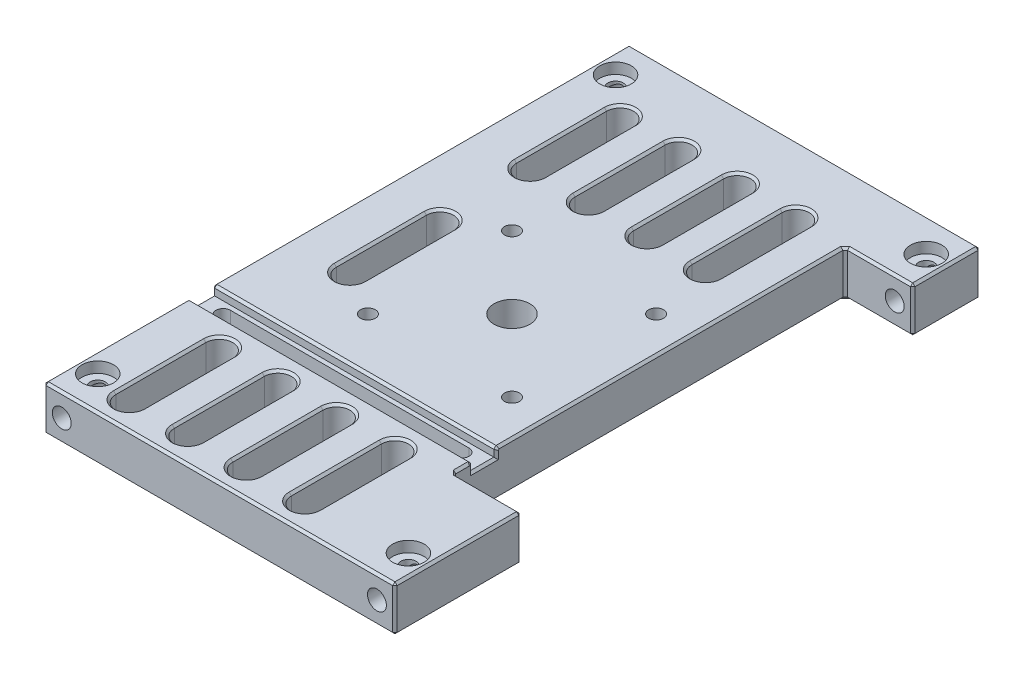
from build123d import *

# Parameters (mm, degrees)
ESQUISSE1_W                                        = 78
ESQUISSE1_H                                        = 10
BOSS_EXTRU_1_DEPTH                                 = 130
TROU_TARAUD_M5X0_81_D                              = 4.2
TROU_TARAUD_M5X0_81_DEPTH                          = 20
TROU_TARAUD_M5X0_81_TIP                            = 1.2618073
TROU_TARAUD_M5X0_82_D                              = 4.2
TROU_TARAUD_M5X0_82_DEPTH                          = 20
TROU_TARAUD_M5X0_82_TIP                            = 1.2618073
TROU_TARAUD_3_8_161_D                              = 7.9375
ESQUISSE9_W                                        = 28.652769352
ESQUISSE9_H                                        = 87
ENL_V_MAT_EXTRU_1_DEPTH                            = 11
ESQUISSE10_W                                       = 68.548519831
ESQUISSE10_H                                       = 5.2
ENL_V_MAT_EXTRU_2_DEPTH                            = 2
CHANFREIN1_SIZE                                    = 0.5
ENL_V_MAT_EXTRU_3_DEPTH                            = 11
ENL_V_MAT_EXTRU_4_DEPTH                            = 3.5
TROU_TARAUD_M4X0_71_D                              = 3.3
TROU_TARAUD_M4X0_71_DEPTH                          = 10
CHAMBRAGE_POUR_VIS_T_TE_RONDE_BOMB_E_M_D           = 3.4
CHAMBRAGE_POUR_VIS_T_TE_RONDE_BOMB_E_M_CBORE_D     = 7
CHAMBRAGE_POUR_VIS_T_TE_RONDE_BOMB_E_M_CBORE_DEPTH = 2.4
ENL_V_MAT_EXTRU_5_DEPTH                            = 10
CHANFREIN2_SIZE                                    = 0.5
CHANFREIN3_SIZE                                    = 0.5


with BuildPart() as part:
    # Esquisse1 → Boss.-Extru.1 (new body)
    with BuildSketch(Plane.XY):
        with Locations((0, -4.782828283)):
            Rectangle(ESQUISSE1_W, ESQUISSE1_H)
    extrude(amount=BOSS_EXTRU_1_DEPTH)

    # Trou taraudé M5x0.81
    with Locations(Plane(origin=(-35, -4.782828283, 130), x_dir=(1, 0, 0), z_dir=(0, 0, 1))):
        with Locations((0, 0), (70, 0)):
            Hole(TROU_TARAUD_M5X0_81_D / 2, depth=TROU_TARAUD_M5X0_81_DEPTH)
            with Locations((0, 0, -(TROU_TARAUD_M5X0_81_DEPTH + TROU_TARAUD_M5X0_81_TIP / 2))):  # 118° drill point
                Cone(0, TROU_TARAUD_M5X0_81_D / 2, TROU_TARAUD_M5X0_81_TIP, mode=Mode.SUBTRACT)

    # Trou taraudé M5x0.82
    with Locations(Plane(origin=(0, 0, 0), x_dir=(-1, 0, 0), z_dir=(0, 0, -1))):
        with Locations((-35, -4.782828283), (35, -4.782828283)):
            Hole(TROU_TARAUD_M5X0_82_D / 2, depth=TROU_TARAUD_M5X0_82_DEPTH)
            with Locations((0, 0, -(TROU_TARAUD_M5X0_82_DEPTH + TROU_TARAUD_M5X0_82_TIP / 2))):  # 118° drill point
                Cone(0, TROU_TARAUD_M5X0_82_D / 2, TROU_TARAUD_M5X0_82_TIP, mode=Mode.SUBTRACT)

    # Trou taraudé 3/8-161 (through all)
    with Locations(Plane(origin=(0, -9.782828283, 65), x_dir=(0, 0, -1), z_dir=(0, -1, 0))):
        with Locations((0, 0)):
            Hole(TROU_TARAUD_3_8_161_D / 2)

    # Esquisse9 → Enlèv. mat.-Extru.1 (cut, through all)
    with BuildSketch(Plane(origin=(0, 0.217171717, 0), x_dir=(1, 0, 0), z_dir=(0, 1, 0))):
        with Locations((38.326384676, -58.5)):
            Rectangle(ESQUISSE9_W, ESQUISSE9_H)
    extrude(amount=-ENL_V_MAT_EXTRU_1_DEPTH, mode=Mode.SUBTRACT)

    # Esquisse10 → Enlèv. mat.-Extru.2 (cut)
    with BuildSketch(Plane(origin=(0, 0.217171717, 0), x_dir=(1, 0, 0), z_dir=(0, 1, 0))):
        with Locations((-9.488541349, -95.15)):
            Rectangle(ESQUISSE10_W, ESQUISSE10_H)
    extrude(amount=-ENL_V_MAT_EXTRU_2_DEPTH, mode=Mode.SUBTRACT)

    # Chanfrein1
    chanfrein1_edges = [part.edges().sort_by_distance(p)[0] for p in [
        (-7.5, 0.217171717, 97.75),
        (-7.5, 0.217171717, 92.55),
    ]]
    chamfer(chanfrein1_edges, length=CHANFREIN1_SIZE)

    # Esquisse12 → Enlèv. mat.-Extru.3 (cut, through all)
    with BuildSketch(Plane(origin=(0, -9.782828283, 0), x_dir=(-1, 0, 0), z_dir=(0, -1, 0))):
        with BuildLine():
            Line((-19, -93.55), (34, -93.55))
            ThreePointArc((34, -93.55), (35.6, -95.15), (34, -96.75))
            Line((34, -96.75), (-19, -96.75))
            ThreePointArc((-19, -96.75), (-20.6, -95.15), (-19, -93.55))
        make_face()
    extrude(amount=-ENL_V_MAT_EXTRU_3_DEPTH, mode=Mode.SUBTRACT)

    # Esquisse13 → Enlèv. mat.-Extru.4 (cut)
    with BuildSketch(Plane(origin=(0, -9.782828283, 0), x_dir=(-1, 0, 0), z_dir=(0, -1, 0))):
        with BuildLine():
            Line((-19, -92.15), (34, -92.15))
            ThreePointArc((34, -92.15), (37, -95.15), (34, -98.15))
            Line((34, -98.15), (-19, -98.15))
            ThreePointArc((-19, -98.15), (-22, -95.15), (-19, -92.15))
        make_face()
    extrude(amount=-ENL_V_MAT_EXTRU_4_DEPTH, mode=Mode.SUBTRACT)

    # Trou taraudé M4x0.71
    with Locations(Plane(origin=(-16, -9.782828283, 49), x_dir=(0, 0, -1), z_dir=(0, -1, 0))):
        with Locations((0, 0), (-32, 0), (-32, 32), (0, 32)):
            Hole(TROU_TARAUD_M4X0_71_D / 2, depth=TROU_TARAUD_M4X0_71_DEPTH)

    # Chambrage pour vis à tête ronde bombée M32 (through all)
    with Locations(Plane(origin=(0, 0.217171717, 0), x_dir=(1, 0, 0), z_dir=(0, 1, 0))):
        with Locations((-34.5, -122.5), (34.5, -122.5), (-34.5, -7.5), (34.5, -7.5)):
            CounterBoreHole(CHAMBRAGE_POUR_VIS_T_TE_RONDE_BOMB_E_M_D / 2, CHAMBRAGE_POUR_VIS_T_TE_RONDE_BOMB_E_M_CBORE_D / 2, CHAMBRAGE_POUR_VIS_T_TE_RONDE_BOMB_E_M_CBORE_DEPTH)

    # Esquisse22 → Enlèv. mat.-Extru.5 (cut)
    with BuildSketch(Plane.XZ.offset(9.782828283)):
        with BuildLine():
            Line((-29, 55), (-29, 75))
            ThreePointArc((-29, 75), (-26, 78), (-23, 75))
            Line((-23, 75), (-23, 55))
            ThreePointArc((-23, 55), (-26, 52), (-29, 55))
        make_face()
        with BuildLine():
            Line((-29, 15), (-29, 35))
            ThreePointArc((-29, 35), (-26, 38), (-23, 35))
            Line((-23, 35), (-23, 15))
            ThreePointArc((-23, 15), (-26, 12), (-29, 15))
        make_face()
        with BuildLine():
            Line((-16, 15), (-16, 35))
            ThreePointArc((-16, 35), (-13, 38), (-10, 35))
            Line((-10, 35), (-10, 15))
            ThreePointArc((-10, 15), (-13, 12), (-16, 15))
        make_face()
        with BuildLine():
            Line((-3, 15), (-3, 35))
            ThreePointArc((-3, 35), (0, 38), (3, 35))
            Line((3, 35), (3, 15))
            ThreePointArc((3, 15), (0, 12), (-3, 15))
        make_face()
        with BuildLine():
            Line((10, 15), (10, 35))
            ThreePointArc((10, 35), (13, 38), (16, 35))
            Line((16, 35), (16, 15))
            ThreePointArc((16, 15), (13, 12), (10, 15))
        make_face()
        with BuildLine():
            Line((-29, 104), (-29, 124))
            ThreePointArc((-29, 124), (-26, 127), (-23, 124))
            Line((-23, 124), (-23, 104))
            ThreePointArc((-23, 104), (-26, 101), (-29, 104))
        make_face()
        with BuildLine():
            Line((-16, 104), (-16, 124))
            ThreePointArc((-16, 124), (-13, 127), (-10, 124))
            Line((-10, 124), (-10, 104))
            ThreePointArc((-10, 104), (-13, 101), (-16, 104))
        make_face()
        with BuildLine():
            Line((-3, 104), (-3, 124))
            ThreePointArc((-3, 124), (0, 127), (3, 124))
            Line((3, 124), (3, 104))
            ThreePointArc((3, 104), (0, 101), (-3, 104))
        make_face()
        with BuildLine():
            Line((10, 104), (10, 124))
            ThreePointArc((10, 124), (13, 127), (16, 124))
            Line((16, 124), (16, 104))
            ThreePointArc((16, 104), (13, 101), (10, 104))
        make_face()
    extrude(amount=-ENL_V_MAT_EXTRU_5_DEPTH, mode=Mode.SUBTRACT)

    # Chanfrein2
    chanfrein2_edges = [part.edges().sort_by_distance(p)[0] for p in [
        (39, -4.782828283, 130),
        (0, 0.217171717, 130),
        (39, 0.217171717, 7.5),
        (39, -9.782828283, 7.5),
        (31.5, 0.217171717, 102),
        (31.5, 0.217171717, 15),
        (24, 0.217171717, 53.525),
        (31.5, -9.782828283, 102),
        (39, -4.782828283, 102),
        (39, -4.782828283, 15),
        (31.5, -9.782828283, 15),
        (24, -4.782828283, 15),
        (24, -9.782828283, 58.5),
        (24, -4.782828283, 102),
        (-39, -4.782828283, 130),
        (0, 0.217171717, 0),
        (39, -4.782828283, 0),
        (0, -9.782828283, 0),
        (-39, -4.782828283, 0),
        (24, -1.782828283, 95.15),
        (24, -1.032828283, 97.75),
        (-39, -1.032828283, 92.55),
        (-39, -1.782828283, 95.15),
        (-39, 0.217171717, 114.125),
        (39, 0.217171717, 116),
        (39, -9.782828283, 116),
        (-39, -9.782828283, 65),
        (24, -1.032828283, 92.55),
        (0, -9.782828283, 130),
        (-39, 0.217171717, 46.025),
        (-39, -1.032828283, 97.75),
        (-39, -0.032828283, 98),
        (-39, -0.032828283, 92.3),
        (24, 0.217171717, 100.125),
        (24, -0.032828283, 98),
        (24, -0.032828283, 92.3),
    ]]
    chamfer(chanfrein2_edges, length=CHANFREIN2_SIZE)

    # Chanfrein3
    chanfrein3_edges = [part.edges().sort_by_distance(p)[0] for p in [
        (13, 0.217171717, 101),
        (10, 0.217171717, 114),
        (13, 0.217171717, 127),
        (16, 0.217171717, 114),
        (13, -9.782828283, 101),
        (16, -9.782828283, 114),
        (13, -9.782828283, 127),
        (10, -9.782828283, 114),
        (0, 0.217171717, 101),
        (-3, 0.217171717, 114),
        (0, 0.217171717, 127),
        (3, 0.217171717, 114),
        (0, -9.782828283, 101),
        (3, -9.782828283, 114),
        (0, -9.782828283, 127),
        (-3, -9.782828283, 114),
        (-13, 0.217171717, 101),
        (-16, 0.217171717, 114),
        (-13, 0.217171717, 127),
        (-10, 0.217171717, 114),
        (-13, -9.782828283, 101),
        (-10, -9.782828283, 114),
        (-13, -9.782828283, 127),
        (-16, -9.782828283, 114),
        (-26, 0.217171717, 101),
        (-29, 0.217171717, 114),
        (-26, 0.217171717, 127),
        (-23, 0.217171717, 114),
        (-26, -9.782828283, 101),
        (-23, -9.782828283, 114),
        (-26, -9.782828283, 127),
        (-29, -9.782828283, 114),
        (13, 0.217171717, 12),
        (10, 0.217171717, 25),
        (13, 0.217171717, 38),
        (16, 0.217171717, 25),
        (13, -9.782828283, 12),
        (16, -9.782828283, 25),
        (13, -9.782828283, 38),
        (10, -9.782828283, 25),
        (0, 0.217171717, 12),
        (-3, 0.217171717, 25),
        (0, 0.217171717, 38),
        (3, 0.217171717, 25),
        (0, -9.782828283, 12),
        (3, -9.782828283, 25),
        (0, -9.782828283, 38),
        (-3, -9.782828283, 25),
        (-13, 0.217171717, 12),
        (-16, 0.217171717, 25),
        (-13, 0.217171717, 38),
        (-10, 0.217171717, 25),
        (-13, -9.782828283, 12),
        (-10, -9.782828283, 25),
        (-13, -9.782828283, 38),
        (-16, -9.782828283, 25),
        (-26, 0.217171717, 12),
        (-29, 0.217171717, 25),
        (-26, 0.217171717, 38),
        (-23, 0.217171717, 25),
        (-26, -9.782828283, 12),
        (-23, -9.782828283, 25),
        (-26, -9.782828283, 38),
        (-29, -9.782828283, 25),
        (-26, 0.217171717, 52),
        (-29, 0.217171717, 65),
        (-26, 0.217171717, 78),
        (-23, 0.217171717, 65),
        (-26, -9.782828283, 52),
        (-23, -9.782828283, 65),
        (-26, -9.782828283, 78),
        (-29, -9.782828283, 65),
    ]]
    chamfer(chanfrein3_edges, length=CHANFREIN3_SIZE)


solid = part.part
